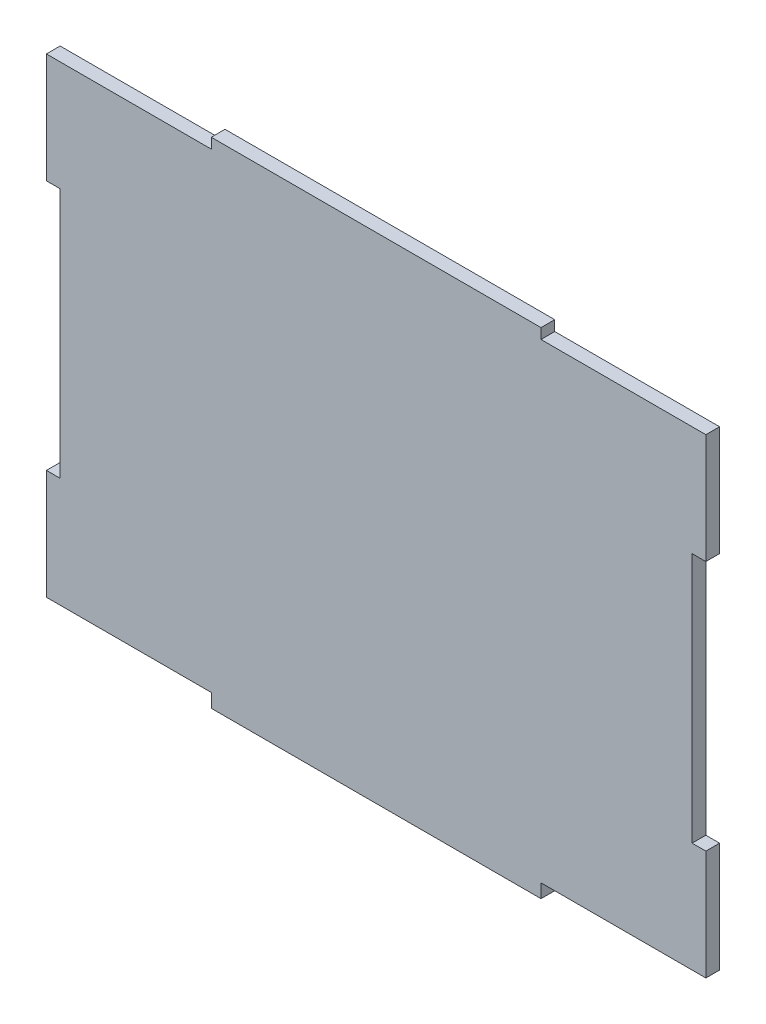
from build123d import *

# Parameters (mm, degrees)
SKETCH_1_W          = 96
SKETCH_1_H          = 72
EXTRUDE_1_DEPTH     = 2
SKETCH_2_W          = 24
SKETCH_2_H          = 2
CUT_EXTRUDE_1_DEPTH = 3
SKETCH_3_W          = 2
SKETCH_3_H          = 36.5
CUT_EXTRUDE_2_DEPTH = 3
SKETCH_4_W          = 2
SKETCH_4_H          = 36.5
CUT_EXTRUDE_3_DEPTH = 3


with BuildPart() as part:
    # ｽｹｯﾁ1 → ﾎﾞｽ - 押し出し1 (new body)
    with BuildSketch(Plane.XY):
        with Locations((2.027244426, 13.573770492)):
            Rectangle(SKETCH_1_W, SKETCH_1_H)
    extrude(amount=EXTRUDE_1_DEPTH)

    # ｽｹｯﾁ2 → ｶｯﾄ - 押し出し1 (cut, through all)
    with BuildSketch(Plane(origin=(0, 0, 0), x_dir=(-1, 0, 0), z_dir=(0, 0, -1))):
        with Locations((33.972755574, -21.426229508)):
            Rectangle(SKETCH_2_W, SKETCH_2_H)
        with Locations((-38.027244426, -21.426229508)):
            Rectangle(SKETCH_2_W, SKETCH_2_H)
        with Locations((33.972755574, 49.073770492)):
            Rectangle(SKETCH_2_W, SKETCH_2_H)
        with Locations((-38.027244426, 49.073770492)):
            Rectangle(SKETCH_2_W, SKETCH_2_H)
    extrude(amount=-CUT_EXTRUDE_1_DEPTH, mode=Mode.SUBTRACT)

    # ｽｹｯﾁ3 → ｶｯﾄ - 押し出し2 (cut, through all)
    with BuildSketch(Plane(origin=(0, 0, 0), x_dir=(-1, 0, 0), z_dir=(0, 0, -1))):
        with Locations((44.972755574, 13.823770492)):
            Rectangle(SKETCH_3_W, SKETCH_3_H)
    extrude(amount=-CUT_EXTRUDE_2_DEPTH, mode=Mode.SUBTRACT)

    # ｽｹｯﾁ4 → ｶｯﾄ - 押し出し3 (cut, through all)
    with BuildSketch(Plane(origin=(0, 0, 0), x_dir=(-1, 0, 0), z_dir=(0, 0, -1))):
        with Locations((-49.027244426, 13.823770492)):
            Rectangle(SKETCH_4_W, SKETCH_4_H)
    extrude(amount=-CUT_EXTRUDE_3_DEPTH, mode=Mode.SUBTRACT)


solid = part.part
